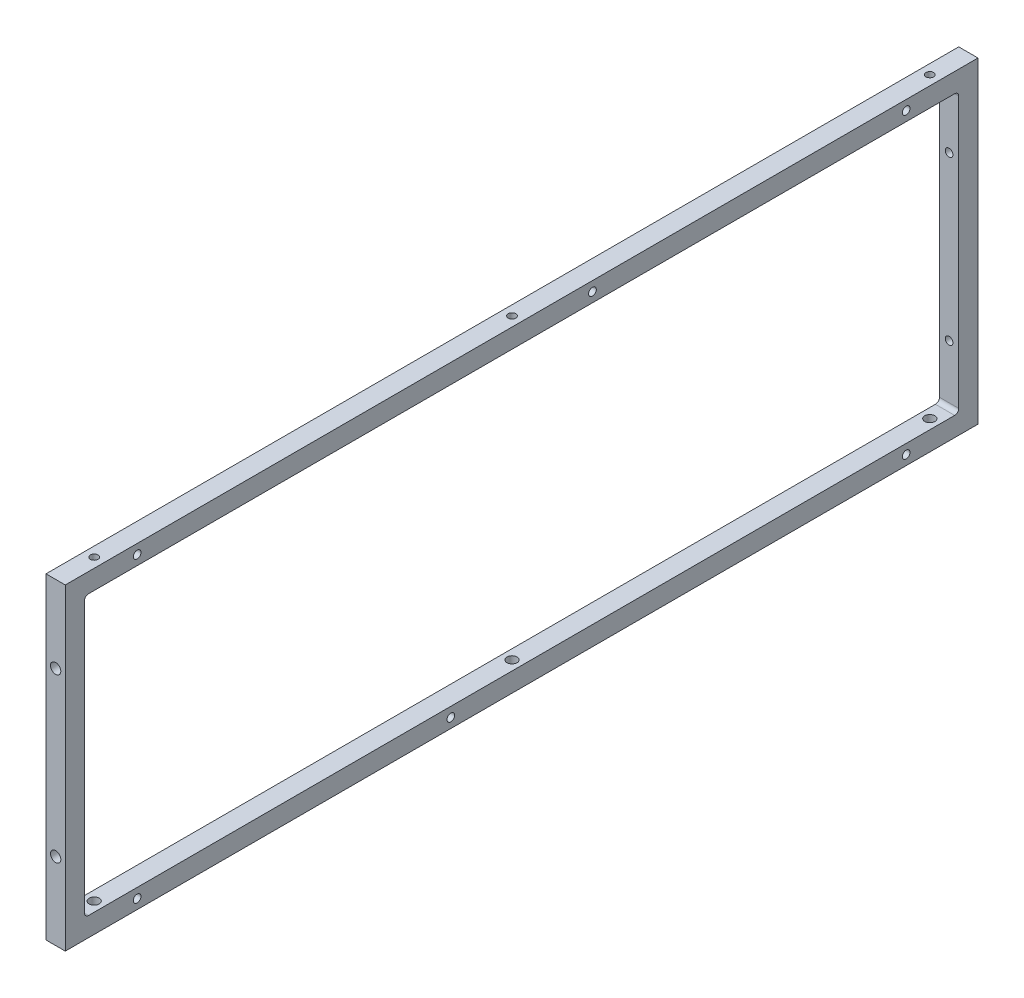
from build123d import *

# Parameters (mm, degrees)
SKETCH1_W                  = 451
SKETCH1_H                  = 156.7072167
SKETCH1_W_2                = 431.95
SKETCH1_H_2                = 137.6572167
EXTRUDE_THIN1_DEPTH        = 4.7625
FILLET1_R                  = 2
F_10_CLEARANCE_HOLE1_D     = 4.9784
F_10_CLEARANCE_HOLE1_DEPTH = 9.525
F_10_24_TAPPED_HOLE1_D     = 3.7973
F_10_24_TAPPED_HOLE1_DEPTH = 250.46
F_10_24_TAPPED_HOLE1_TIP   = 1.140824014
F_10_CLEARANCE_HOLE2_D     = 5.1054
F_10_CLEARANCE_HOLE2_DEPTH = 20
F_10_CLEARANCE_HOLE2_TIP   = 1.533816902
F_10_24_TAPPED_HOLE2_D     = 3.7973
F_10_24_TAPPED_HOLE2_DEPTH = 14.95
F_10_24_TAPPED_HOLE2_TIP   = 1.140824014
F_10_24_TAPPED_HOLE3_D     = 3.7973
F_10_24_TAPPED_HOLE3_DEPTH = 14.95
F_10_24_TAPPED_HOLE3_TIP   = 1.140824014


with BuildPart() as part:
    # Sketch1 → Extrude-Thin1 (new body, symmetric)
    with BuildSketch(Plane(origin=(0, 0, 0), x_dir=(0, 0, -1), z_dir=(1, 0, 0))):
        Rectangle(SKETCH1_W, SKETCH1_H)
        Rectangle(SKETCH1_W_2, SKETCH1_H_2, mode=Mode.SUBTRACT)
    extrude(amount=EXTRUDE_THIN1_DEPTH, both=True)

    # Fillet1
    fillet1_edges = [part.edges().sort_by_distance(p)[0] for p in [
        (0, 68.82860835, 215.975),
        (0, -68.82860835, 215.975),
        (0, -68.82860835, -215.975),
        (0, 68.82860835, -215.975),
    ]]
    fillet(fillet1_edges, radius=FILLET1_R)

    # #10 Clearance Hole1
    with Locations(Plane(origin=(0, -68.82860835, 0), x_dir=(1, 0, 0), z_dir=(0, 1, 0))):
        with Locations((0, 206.45), (0, 0), (0, -206.45)):
            Hole(F_10_CLEARANCE_HOLE1_D / 2, depth=F_10_CLEARANCE_HOLE1_DEPTH)

    # #10-24 Tapped Hole1
    with Locations(Plane(origin=(0, 0, -225.5), x_dir=(-1, 0, 0), z_dir=(0, 0, -1))):
        with Locations((0, 40.25360835), (0, -40.25360835)):
            Hole(F_10_24_TAPPED_HOLE1_D / 2, depth=F_10_24_TAPPED_HOLE1_DEPTH)
            with Locations((0, 0, -(F_10_24_TAPPED_HOLE1_DEPTH + F_10_24_TAPPED_HOLE1_TIP / 2))):  # 118° drill point
                Cone(0, F_10_24_TAPPED_HOLE1_D / 2, F_10_24_TAPPED_HOLE1_TIP, mode=Mode.SUBTRACT)

    # #10 Clearance Hole2
    with Locations(Plane.XY.offset(225.5)):
        with Locations((0, 40.25360835), (0, -40.25360835)):
            Hole(F_10_CLEARANCE_HOLE2_D / 2, depth=F_10_CLEARANCE_HOLE2_DEPTH)
            with Locations((0, 0, -(F_10_CLEARANCE_HOLE2_DEPTH + F_10_CLEARANCE_HOLE2_TIP / 2))):  # 118° drill point
                Cone(0, F_10_CLEARANCE_HOLE2_D / 2, F_10_CLEARANCE_HOLE2_TIP, mode=Mode.SUBTRACT)

    # #10-24 Tapped Hole2
    with Locations(Plane.ZY.offset(4.7625)):
        with Locations((-190, 73.59110835), (-35, 73.59110835), (-190, -73.59110835), (35, -73.59110835), (190, -73.59110835), (190, 73.59110835)):
            Hole(F_10_24_TAPPED_HOLE2_D / 2, depth=F_10_24_TAPPED_HOLE2_DEPTH)
            with Locations((0, 0, -(F_10_24_TAPPED_HOLE2_DEPTH + F_10_24_TAPPED_HOLE2_TIP / 2))):  # 118° drill point
                Cone(0, F_10_24_TAPPED_HOLE2_D / 2, F_10_24_TAPPED_HOLE2_TIP, mode=Mode.SUBTRACT)

    # #10-24 Tapped Hole3
    with Locations(Plane(origin=(0, 78.35360835, 0), x_dir=(1, 0, 0), z_dir=(0, 1, 0))):
        with Locations((0, 206.45), (0, 0), (0, -206.45)):
            Hole(F_10_24_TAPPED_HOLE3_D / 2, depth=F_10_24_TAPPED_HOLE3_DEPTH)
            with Locations((0, 0, -(F_10_24_TAPPED_HOLE3_DEPTH + F_10_24_TAPPED_HOLE3_TIP / 2))):  # 118° drill point
                Cone(0, F_10_24_TAPPED_HOLE3_D / 2, F_10_24_TAPPED_HOLE3_TIP, mode=Mode.SUBTRACT)


solid = part.part
